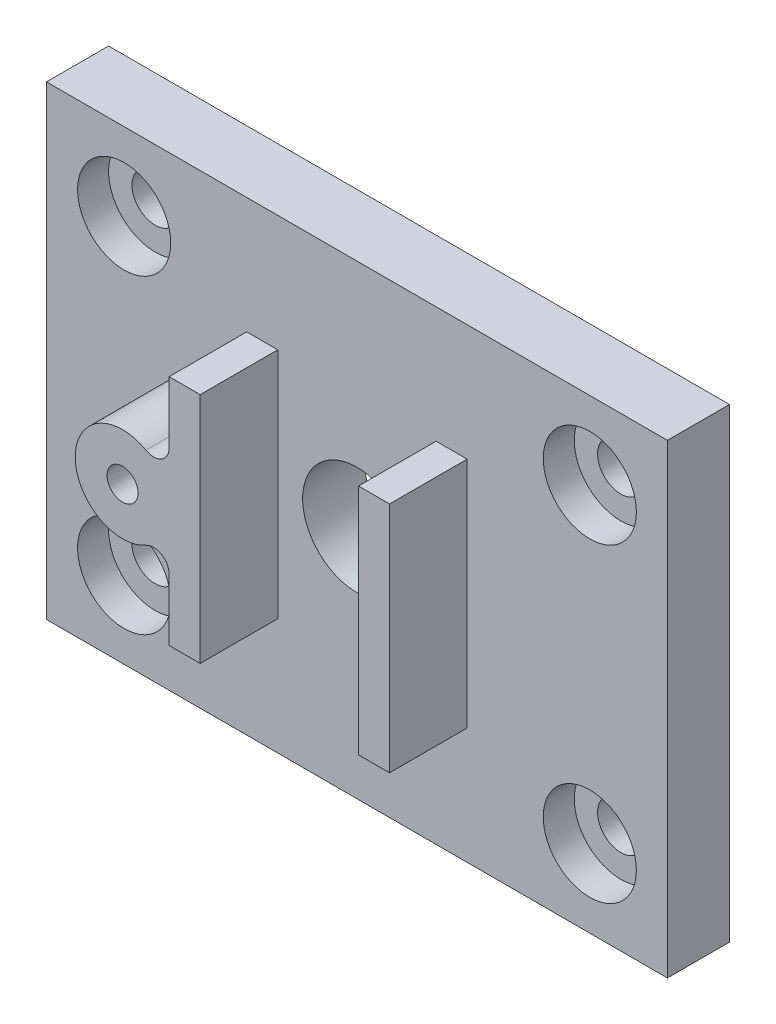
from build123d import *

# Parameters (mm, degrees)
SKIZZE1_W                       = 40
SKIZZE1_H                       = 30
SKIZZE1_R                       = 3
SKIZZE1_R_2                     = 3.5
AUFSATZ_LINEAR_AUSTRAGEN1_DEPTH = 4
SKIZZE1_3_R                     = 3
SKIZZE1_3_R_2                   = 1.5
AUFSATZ_LINEAR_AUSTRAGEN2_DEPTH = 2
SKIZZE2_R                       = 1
SKIZZE2_W                       = 2
SKIZZE2_H                       = 15
AUFSATZ_LINEAR_AUSTRAGEN5_DEPTH = 5
VERRUNDUNG1_R                   = 1


with BuildPart() as part:
    # Skizze1 → Aufsatz-Linear austragen1 (new body)
    with BuildSketch(Plane.XY):
        with Locations((20, 15)):
            Rectangle(SKIZZE1_W, SKIZZE1_H)
        with Locations((5, 5)):
            Circle(SKIZZE1_R, mode=Mode.SUBTRACT)
        with Locations((35, 5)):
            Circle(SKIZZE1_R, mode=Mode.SUBTRACT)
        with Locations((5, 25)):
            Circle(SKIZZE1_R, mode=Mode.SUBTRACT)
        with Locations((20, 15)):
            Circle(SKIZZE1_R_2, mode=Mode.SUBTRACT)
        with Locations((35, 25)):
            Circle(SKIZZE1_R, mode=Mode.SUBTRACT)
    extrude(amount=AUFSATZ_LINEAR_AUSTRAGEN1_DEPTH)

    # Skizze1_3 → Aufsatz-Linear austragen2 (add)
    # profile 1 of 4: a face of its own
    with BuildSketch(Plane.XY):
        with Locations((5, 25)):
            Circle(SKIZZE1_3_R)
        with Locations((5, 25)):
            Circle(SKIZZE1_3_R_2, mode=Mode.SUBTRACT)
    # profile 2 of 4: a face of its own
    with BuildSketch(Plane.XY):
        with Locations((35, 25)):
            Circle(SKIZZE1_3_R)
        with Locations((35, 25)):
            Circle(SKIZZE1_3_R_2, mode=Mode.SUBTRACT)
    # profile 3 of 4: a face of its own
    with BuildSketch(Plane.XY):
        with Locations((35, 5)):
            Circle(SKIZZE1_3_R)
        with Locations((35, 5)):
            Circle(SKIZZE1_3_R_2, mode=Mode.SUBTRACT)
    # profile 4 of 4: a face of its own
    with BuildSketch(Plane.XY):
        with Locations((5, 5)):
            Circle(SKIZZE1_3_R)
        with Locations((5, 5)):
            Circle(SKIZZE1_3_R_2, mode=Mode.SUBTRACT)
    extrude(amount=AUFSATZ_LINEAR_AUSTRAGEN2_DEPTH)

    # Skizze2 → Aufsatz-Linear austragen5 (add)
    # profile 1 of 2: a face of its own
    with BuildSketch(Plane.XY.offset(4)):
        with BuildLine():
            Line((14.9, 7.5), (14.9, 22.5))
            Line((14.9, 22.5), (12.9, 22.5))
            Line((12.9, 22.5), (12.9, 15.55))
            ThreePointArc((12.9, 15.55), (6.85, 15), (12.9, 14.45))
            Line((12.9, 14.45), (12.9, 7.5))
            Line((12.9, 7.5), (14.9, 7.5))
        make_face()
        with Locations((9.9, 15)):
            Circle(SKIZZE2_R, mode=Mode.SUBTRACT)
    # profile 2 of 2: a face of its own
    with BuildSketch(Plane.XY.offset(4)):
        with Locations((26.1, 15)):
            Rectangle(SKIZZE2_W, SKIZZE2_H)
    extrude(amount=AUFSATZ_LINEAR_AUSTRAGEN5_DEPTH)

    # Verrundung1
    verrundung1_edges = [part.edges().sort_by_distance(p)[0] for p in [
        (12.9, 15.55, 6.5),
        (12.9, 14.45, 6.5),
    ]]
    fillet(verrundung1_edges, radius=VERRUNDUNG1_R)


solid = part.part
